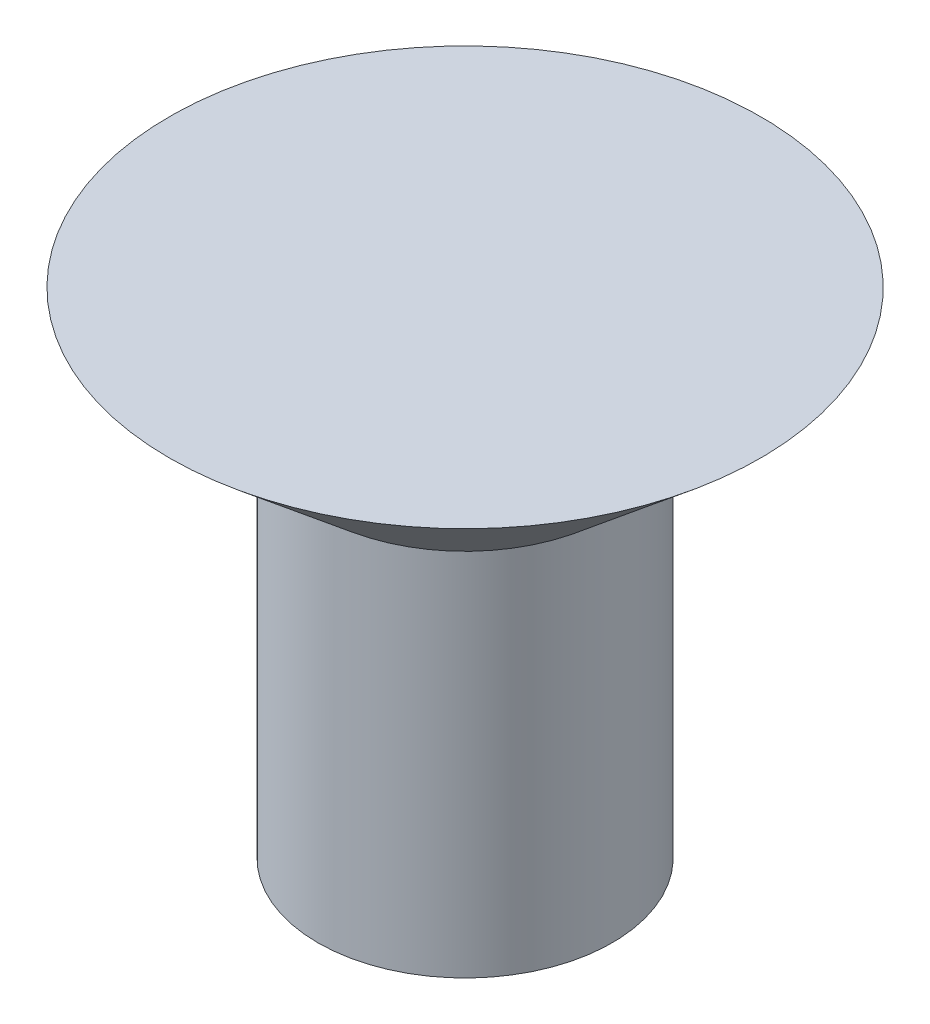
from build123d import *


with BuildPart() as part:
    # Sketch1 → Revolve1 (revolve)
    with BuildSketch(Plane(origin=(0, 0, 0), x_dir=(0, 0, -1), z_dir=(1, 0, 0)), mode=Mode.PRIVATE) as revolve1_sk:
        Polygon((0, 0), (0, -4.7752), (1.4224, -4.7752), (1.4224, -1.204191881), (2.8575, 0), align=None)
    revolve(revolve1_sk.sketch.rotate(Axis((0, 51.060726969, 0), (0, -1, 0)), 180), axis=Axis((0, 51.060726969, 0), (0, -1, 0)))  # turned: the seam where the file's is


solid = part.part
